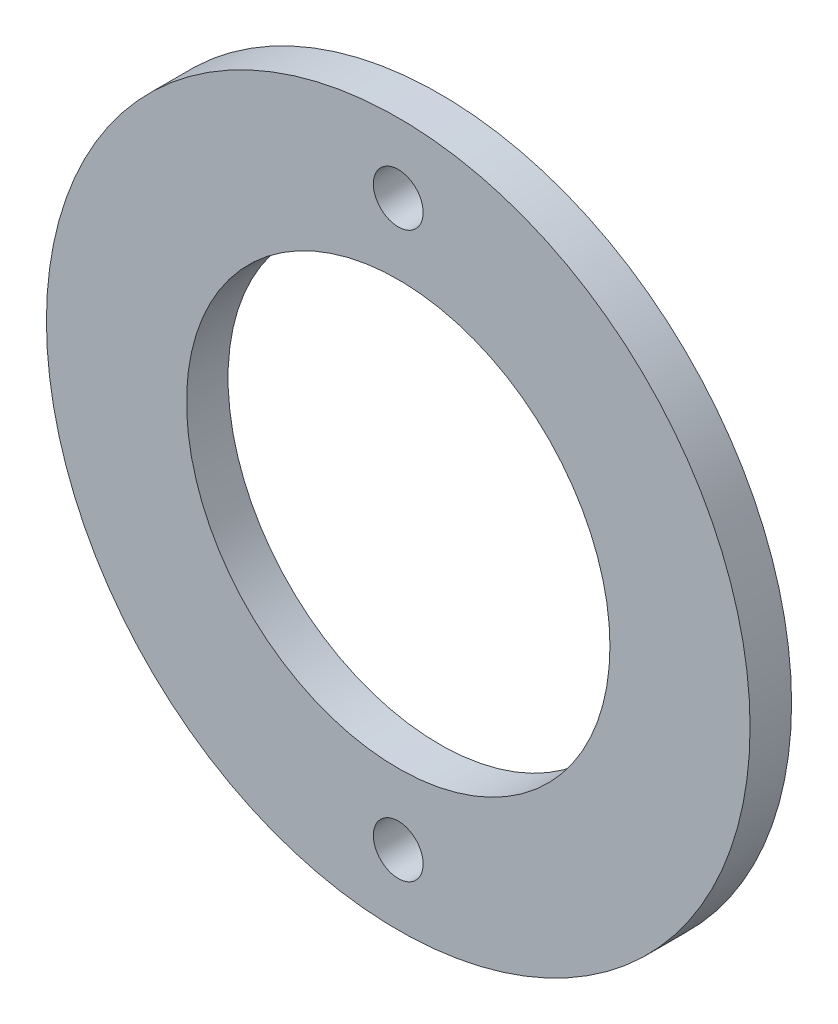
from build123d import *

# Parameters (mm, degrees)
SKETCH1_R           = 26.924
SKETCH1_R_2         = 16.2
SKETCH1_R_3         = 1.905
BOSS_EXTRUDE1_DEPTH = 3.175


with BuildPart() as part:
    # Sketch1 → Boss-Extrude1 (new body)
    with BuildSketch(Plane.XY):
        Circle(SKETCH1_R)
        Circle(SKETCH1_R_2, mode=Mode.SUBTRACT)
        with Locations((0, 21.59)):
            Circle(SKETCH1_R_3, mode=Mode.SUBTRACT)
        with Locations((0, -21.59)):
            Circle(SKETCH1_R_3, mode=Mode.SUBTRACT)
    extrude(amount=BOSS_EXTRUDE1_DEPTH)


solid = part.part
